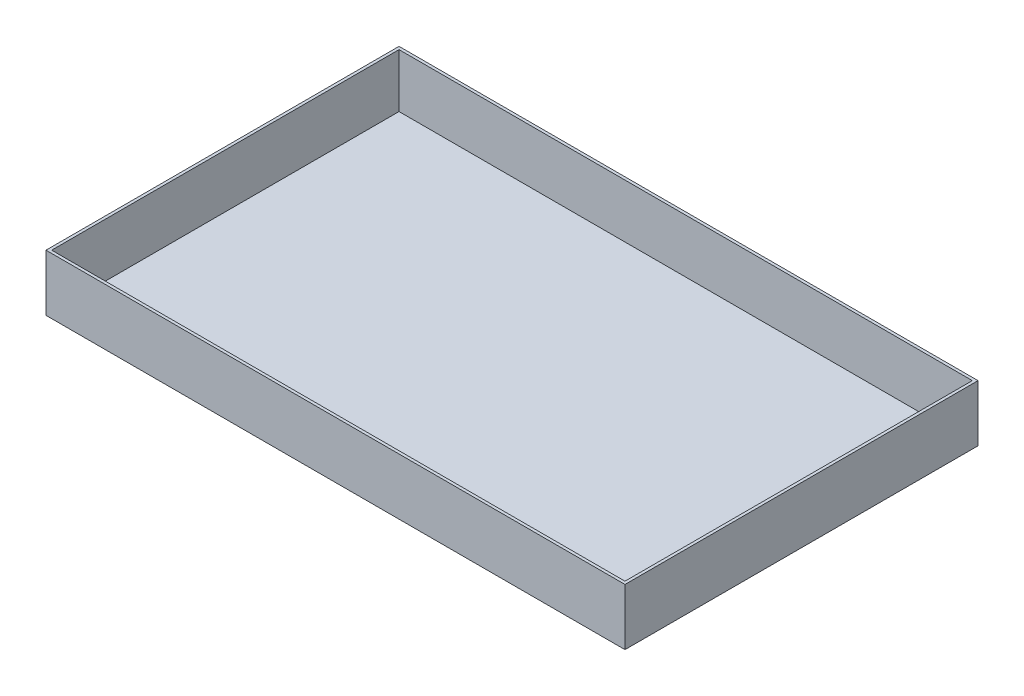
from build123d import *

# Parameters (mm, degrees)
SKETCH_1_W      = 410
SKETCH_1_H      = 250
EXTRUDE_1_DEPTH = 40
SHELL_1_T       = -2


with BuildPart() as part:
    # 草图1 → 凸台-拉伸1 (new body)
    with BuildSketch(Plane(origin=(0, 0, 0), x_dir=(1, 0, 0), z_dir=(0, 1, 0))):
        with Locations((205, 125)):
            Rectangle(SKETCH_1_W, SKETCH_1_H)
    extrude(amount=EXTRUDE_1_DEPTH)

    # 抽壳1
    shell_1_openings = [part.faces().sort_by_distance(p)[0] for p in [
        (205, 40, -125),
    ]]
    offset(amount=SHELL_1_T, openings=shell_1_openings, kind=Kind.INTERSECTION)


solid = part.part
